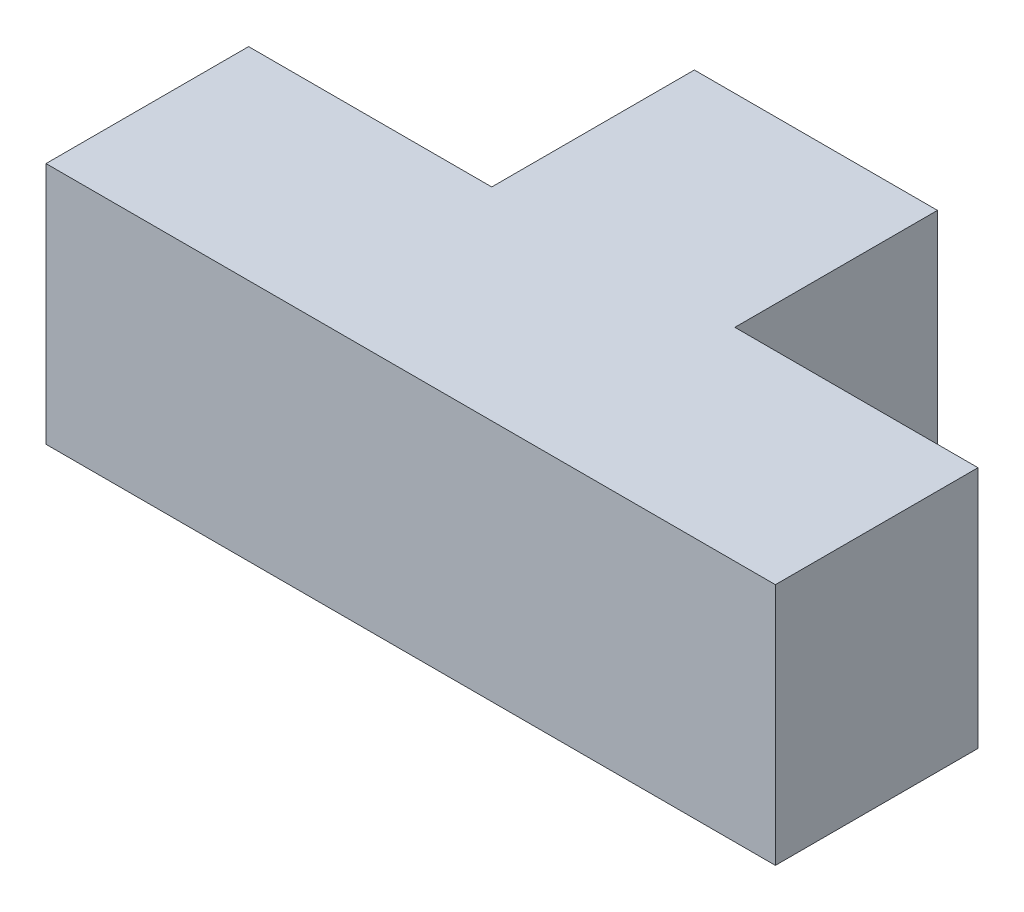
from build123d import *

# Parameters (mm, degrees)
BOSS_EXTRUDE1_DEPTH = 30


with BuildPart() as part:
    # Sketch1 → Boss-Extrude1 (new body)
    with BuildSketch(Plane(origin=(0, 0, 0), x_dir=(1, 0, 0), z_dir=(0, 1, 0))):
        Polygon((30, 50), (60, 50), (60, 25), (90, 25), (90, 0), (0, 0), (0, 25), (30, 25), align=None)
    extrude(amount=BOSS_EXTRUDE1_DEPTH)


solid = part.part
